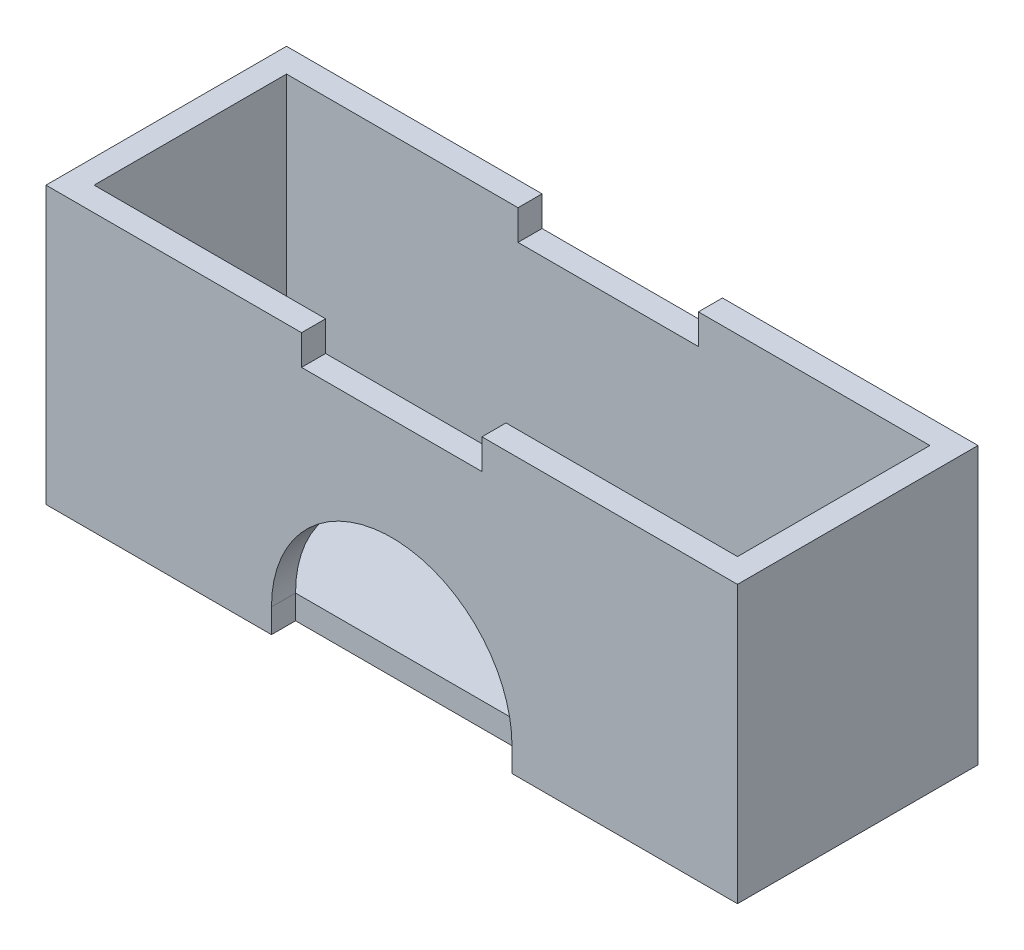
from build123d import *

# Parameters (mm, degrees)
SKETCH1_W           = 146.05
SKETCH1_H           = 50.8
BOSS_EXTRUDE1_DEPTH = 58.42
SHELL1_T            = -5.08
SKETCH2_W           = 50.8
SKETCH2_H           = 5.08
CUT_EXTRUDE2_DEPTH  = 5.08
SKETCH4_W           = 38.1
SKETCH4_H           = 50.8
CUT_EXTRUDE3_DEPTH  = 6.35


with BuildPart() as part:
    # Sketch1 → Boss-Extrude1 (new body)
    with BuildSketch(Plane(origin=(0, 0, 0), x_dir=(1, 0, 0), z_dir=(0, 1, 0))):
        with Locations((73.025, 25.4)):
            Rectangle(SKETCH1_W, SKETCH1_H)
    extrude(amount=BOSS_EXTRUDE1_DEPTH)

    # Shell1
    shell1_openings = [part.faces().sort_by_distance(p)[0] for p in [
        (73.025, 58.42, -25.4),
    ]]
    offset(amount=SHELL1_T, openings=shell1_openings, kind=Kind.INTERSECTION)

    # Sketch2 → Cut-Extrude2 (cut)
    with BuildSketch(Plane.XY):
        with Locations((73.025, 2.54)):
            Rectangle(SKETCH2_W, SKETCH2_H)
        with BuildLine():
            ThreePointArc((98.425, 5.08), (73.025, 30.48), (47.625, 5.08))
            Line((47.625, 5.08), (98.425, 5.08))
        make_face()
    extrude(amount=-CUT_EXTRUDE2_DEPTH, mode=Mode.SUBTRACT)

    # Sketch4 → Cut-Extrude3 (cut)
    with BuildSketch(Plane(origin=(0, 58.42, 0), x_dir=(1, 0, 0), z_dir=(0, 1, 0))):
        with Locations((73.025, 25.4)):
            Rectangle(SKETCH4_W, SKETCH4_H)
    extrude(amount=-CUT_EXTRUDE3_DEPTH, mode=Mode.SUBTRACT)


solid = part.part
